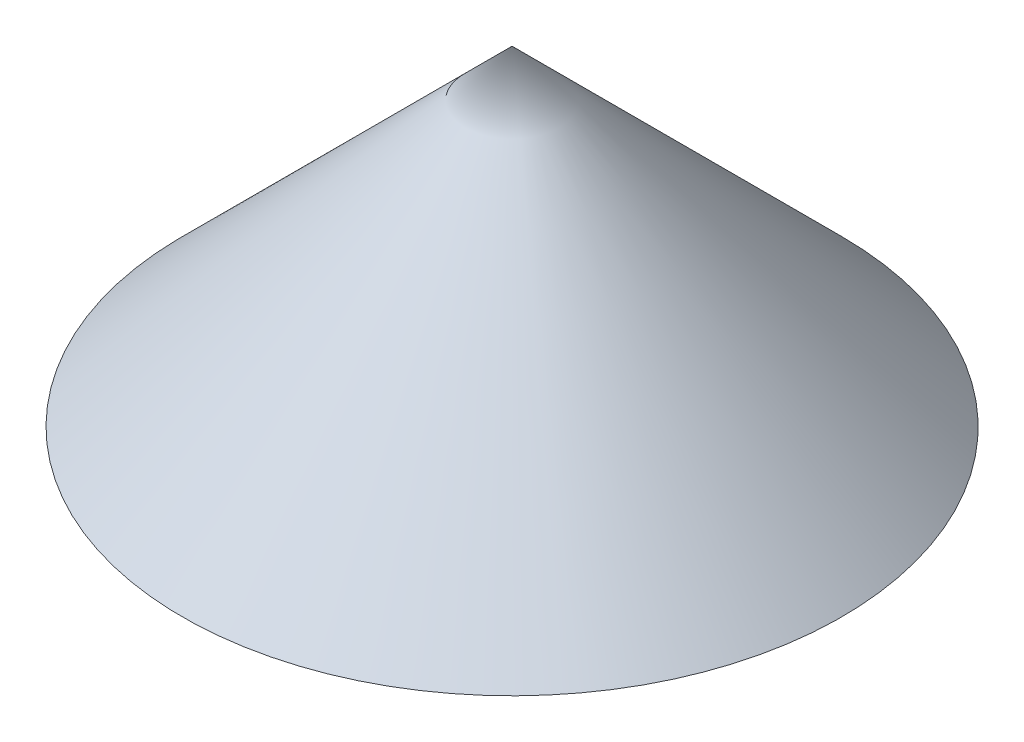
from build123d import *


with BuildPart() as part:
    # Sketch1 → Revolve1 (revolve)
    with BuildSketch(Plane.XY):
        Polygon((0, 0), (0, 42), (42, 0), align=None)
    revolve(axis=Axis((0, 0, 0), (0, 1, 0)))

    # Sketch2 → Cut-Revolve1 (revolve, cut)
    with BuildSketch(Plane.XY):
        Polygon((6.342498429, 31.657501571), (6.342498429, 0), (38, 0), align=None)
    revolve(axis=Axis((0, 0, 0), (0, 1, 0)), mode=Mode.SUBTRACT)


solid = part.part
